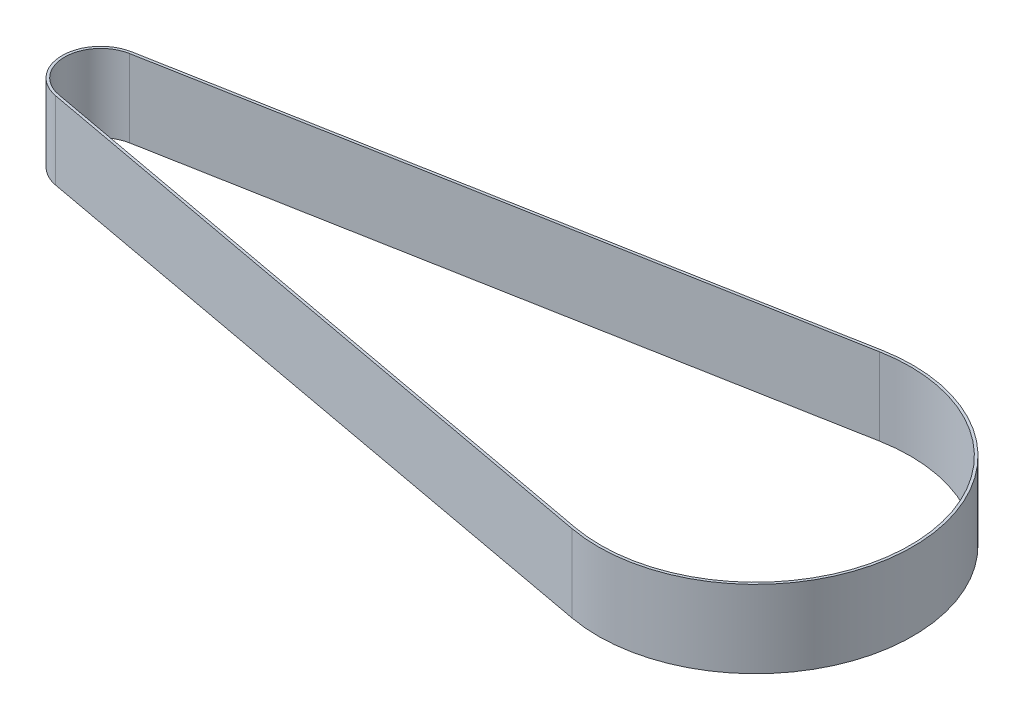
from build123d import *

# Parameters (mm, degrees)
BOSS_EXTRUDE1_DEPTH = 15


with BuildPart() as part:
    # Sketch1 → Boss-Extrude1 (new body)
    with BuildSketch(Plane(origin=(0, 0, 0), x_dir=(1, 0, 0), z_dir=(0, 1, 0))):
        with BuildLine():
            Line((-1.359338061, 7.375784706), (121.372025217, 29.994857806))
            ThreePointArc((121.372025217, 29.994857806), (157.4, 0), (121.372025217, -29.994857806))
            Line((121.372025217, -29.994857806), (-1.359338061, -7.375784706))
            ThreePointArc((-1.359338061, -7.375784706), (-7.5, 0), (-1.359338061, 7.375784706))
        make_face()
        with BuildLine():
            Line((-1.268715524, 6.884065726), (121.462647754, 29.503138825))
            ThreePointArc((121.462647754, 29.503138825), (156.9, 0), (121.462647754, -29.503138825))
            Line((121.462647754, -29.503138825), (-1.268715524, -6.884065726))
            ThreePointArc((-1.268715524, -6.884065726), (-7, 0), (-1.268715524, 6.884065726))
        make_face(mode=Mode.SUBTRACT)
    extrude(amount=BOSS_EXTRUDE1_DEPTH)


solid = part.part
